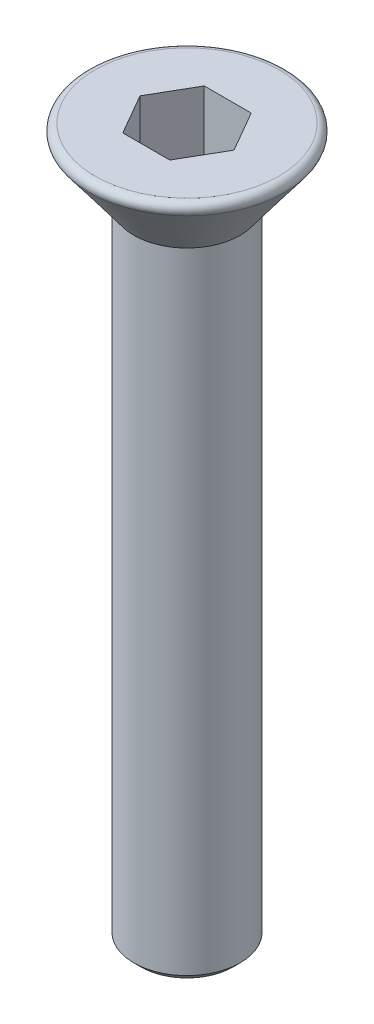
from build123d import *

# Parameters (mm, degrees)
SKETCH_2_R          = 1.5
EXTRUDE_1_DEPTH     = 18
CUT_EXTRUDE_1_DEPTH = 2
CHAMFER_1_SIZE      = 0.2
FILLET_1_R          = 0.2


with BuildPart() as part:
    # 草图1 → 旋转1 (revolve)
    with BuildSketch(Plane.XY):
        Polygon((0, 0), (0, -2), (1.5, -2), (3, 0), align=None)
    revolve(axis=Axis((0, 0, 0), (0, -1, 0)))

    # 草图2 → 凸台-拉伸1 (add)
    with BuildSketch(Plane.XZ.offset(2)):
        Circle(SKETCH_2_R)
    extrude(amount=EXTRUDE_1_DEPTH)

    # 草图3 → 切除-拉伸1 (cut)
    with BuildSketch(Plane(origin=(0, 0, 0), x_dir=(1, 0, 0), z_dir=(0, 1, 0))):
        Polygon((-1.327905619, 0), (-0.66395281, -1.15), (0.66395281, -1.15), (1.327905619, 0), (0.66395281, 1.15), (-0.66395281, 1.15), align=None)
    extrude(amount=-CUT_EXTRUDE_1_DEPTH, mode=Mode.SUBTRACT)

    # 倒角1
    chamfer_1_edges = [part.edges().sort_by_distance(p)[0] for p in [
        (-1.5, -20, 0),
    ]]
    chamfer(chamfer_1_edges, length=CHAMFER_1_SIZE)

    # 圆角1
    fillet_1_edges = [part.edges().sort_by_distance(p)[0] for p in [
        (-3, 0, 0),
    ]]
    fillet(fillet_1_edges, radius=FILLET_1_R)


solid = part.part
